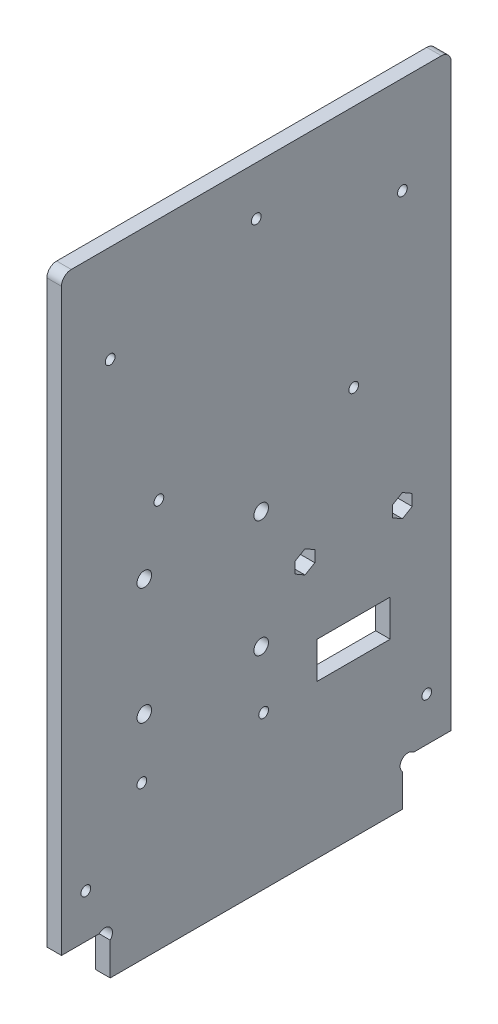
from build123d import *

# Parameters (mm, degrees)
EXTRUSION1_DEPTH        = 3
ESQUISSE2_R             = 1
ESQUISSE2_R_2           = 1.5
ENL_V_MAT_EXTRU_1_DEPTH = 4
ESQUISSE3_W             = 15
ESQUISSE3_H             = 7.5
ENL_V_MAT_EXTRU_2_DEPTH = 4
ESQUISSE4_R             = 1
ENL_V_MAT_EXTRU_3_DEPTH = 4
ENL_V_MAT_EXTRU_4_DEPTH = 4
CONG_1_R                = 2
ESQUISSE6_R             = 1
ENL_V_MAT_EXTRU_5_DEPTH = 4


with BuildPart() as part:
    # Esquisse1 → Extrusion1 (new body)
    with BuildSketch(Plane(origin=(0, 0, 0), x_dir=(0, 0, -1), z_dir=(1, 0, 0))):
        with BuildLine():
            Line((10, 6.7372583), (10, 0))
            Line((10, 0), (70, 0))
            Line((70, 0), (70, 6.7372583))
            ThreePointArc((70, 6.7372583), (70, 9), (72.2627417, 9))
            Line((72.2627417, 9), (80, 9))
            Line((80, 9), (80, 130))
            Line((80, 130), (0, 130))
            Line((0, 130), (0, 9))
            Line((0, 9), (7.7372583, 9))
            ThreePointArc((7.7372583, 9), (10, 9), (10, 6.7372583))
        make_face()
    extrude(amount=EXTRUSION1_DEPTH)

    # Esquisse2 → Enlèv. mat.-Extru.1 (cut, through all)
    with BuildSketch(Plane(origin=(3, 0, 0), x_dir=(0, 0, -1), z_dir=(1, 0, 0))):
        with Locations((60, 80)):
            Circle(ESQUISSE2_R)
        with Locations((10, 110)):
            Circle(ESQUISSE2_R)
        with Locations(Location((20, 80, 0), (0, 0, 180))):  # turned: the seam where the file's is
            Circle(ESQUISSE2_R)
        with Locations((70, 110)):
            Circle(ESQUISSE2_R)
        with Locations((17, 67.45)):
            Circle(ESQUISSE2_R_2)
        with Locations((17, 43.45)):
            Circle(ESQUISSE2_R_2)
        with Locations((41, 43.45)):
            Circle(ESQUISSE2_R_2)
        with Locations((41, 67.45)):
            Circle(ESQUISSE2_R_2)
        with Locations((40, 120)):
            Circle(ESQUISSE2_R)
        with Locations((70, 54)):
            Circle(ESQUISSE2_R)
        with Locations((50, 54)):
            Circle(ESQUISSE2_R)
    extrude(amount=-ENL_V_MAT_EXTRU_1_DEPTH, mode=Mode.SUBTRACT)

    # Esquisse3 → Enlèv. mat.-Extru.2 (cut, through all)
    with BuildSketch(Plane.ZY):
        with Locations((-60, 35.25)):
            Rectangle(ESQUISSE3_W, ESQUISSE3_H)
    extrude(amount=-ENL_V_MAT_EXTRU_2_DEPTH, mode=Mode.SUBTRACT)

    # Esquisse4 → Enlèv. mat.-Extru.3 (cut, through all)
    with BuildSketch(Plane(origin=(3, 0, 0), x_dir=(0, 0, -1), z_dir=(1, 0, 0))):
        with Locations((75, 18)):
            Circle(ESQUISSE4_R)
        with Locations((5, 18)):
            Circle(ESQUISSE4_R)
    extrude(amount=-ENL_V_MAT_EXTRU_3_DEPTH, mode=Mode.SUBTRACT)

    # Esquisse5 → Enlèv. mat.-Extru.4 (cut, through all)
    with BuildSketch(Plane(origin=(3, 0, 0), x_dir=(0, 0, -1), z_dir=(1, 0, 0))):
        Polygon((50, 51.67), (52.017839191, 52.835), (52.017839191, 55.165), (50, 56.33), (47.982160809, 55.165), (47.982160809, 52.835), align=None)
        Polygon((70, 51.67), (72.017839191, 52.835), (72.017839191, 55.165), (70, 56.33), (67.982160809, 55.165), (67.982160809, 52.835), align=None)
    extrude(amount=-ENL_V_MAT_EXTRU_4_DEPTH, mode=Mode.SUBTRACT)

    # Congé1
    cong_1_edges = [part.edges().sort_by_distance(p)[0] for p in [
        (1.5, 130, 0),
        (1.5, 130, -80),
    ]]
    fillet(cong_1_edges, radius=CONG_1_R)

    # Esquisse6 → Enlèv. mat.-Extru.5 (cut, through all)
    with BuildSketch(Plane(origin=(3, 0, 0), x_dir=(0, 0, -1), z_dir=(1, 0, 0))):
        with Locations((16.500002172, 31.460421101)):
            Circle(ESQUISSE6_R)
        with Locations((41.5, 31.45)):
            Circle(ESQUISSE6_R)
    extrude(amount=-ENL_V_MAT_EXTRU_5_DEPTH, mode=Mode.SUBTRACT)


solid = part.part
